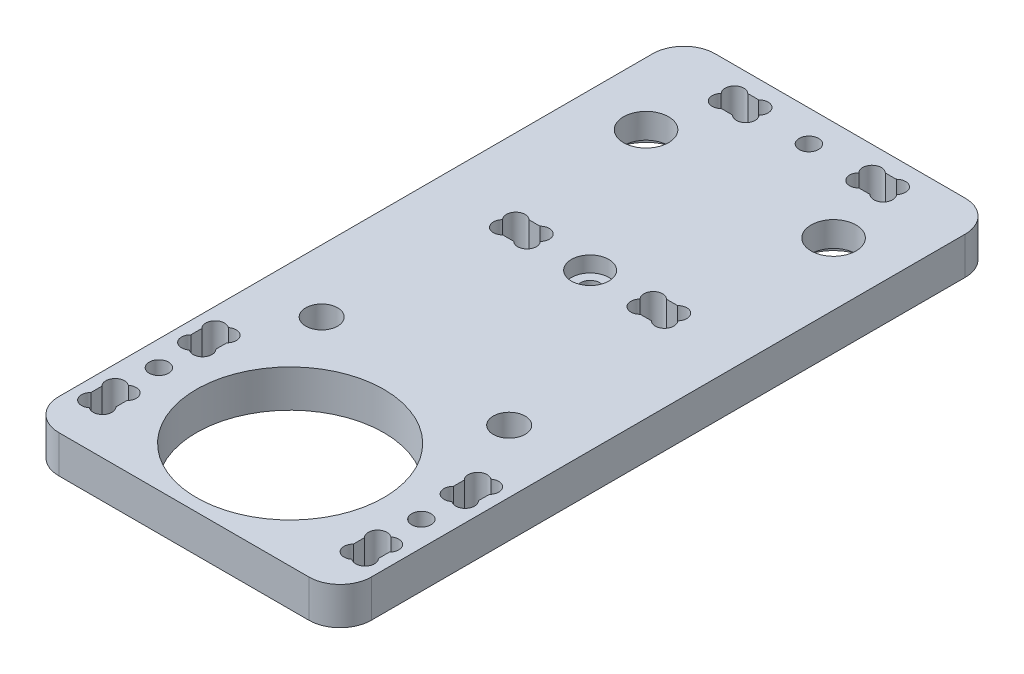
from build123d import *

# Parameters (mm, degrees)
CROQUIS1_W              = 50
CROQUIS1_H              = 105
SALIENTE_EXTRUIR1_DEPTH = 6
CROQUIS2_R              = 3.6
CROQUIS2_R_2            = 2.55
CORTAR_EXTRUIR2_DEPTH   = 7
CROQUIS4_R              = 6
CROQUIS4_R_2            = 5.05
CORTAR_EXTRUIR3_DEPTH   = 2
CROQUIS5_R              = 1.55
CROQUIS5_W              = 6
CROQUIS5_H              = 4.2
CORTAR_EXTRUIR4_DEPTH   = 7
CORTAR_EXTRUIR6_DEPTH   = 7
CROQUIS14_R             = 3
CORTAR_EXTRUIR9_DEPTH   = 2.5
CROQUIS16_R             = 15
CORTAR_EXTRUIR10_DEPTH  = 7
CROQUIS17_R             = 1.55
CROQUIS17_W             = 4
CROQUIS17_H             = 6
CORTAR_EXTRUIR11_DEPTH  = 7
REDONDEO1_R             = 5
CORTAR_EXTRUIR12_DEPTH  = 7


with BuildPart() as part:
    # Croquis1 → Saliente-Extruir1 (new body)
    with BuildSketch(Plane(origin=(0, 0, 0), x_dir=(1, 0, 0), z_dir=(0, 1, 0))):
        Rectangle(CROQUIS1_W, CROQUIS1_H)
    extrude(amount=SALIENTE_EXTRUIR1_DEPTH)

    # Croquis2 → Cortar-Extruir2 (cut, through all)
    with BuildSketch(Plane(origin=(0, 6, 0), x_dir=(1, 0, 0), z_dir=(0, 1, 0))):
        with Locations((-15, 36.45)):
            Circle(CROQUIS2_R)
        with Locations((15, 36.45)):
            Circle(CROQUIS2_R)
        with Locations((15, -15.45)):
            Circle(CROQUIS2_R_2)
        with Locations((-15, -15.45)):
            Circle(CROQUIS2_R_2)
    extrude(amount=-CORTAR_EXTRUIR2_DEPTH, mode=Mode.SUBTRACT)

    # Croquis4 → Cortar-Extruir3 (cut)
    with BuildSketch(Plane.XZ):
        with Locations((15, -36.45)):
            Circle(CROQUIS4_R)
        with Locations((-15, -36.45)):
            Circle(CROQUIS4_R)
        with Locations((-15, 15.45)):
            Circle(CROQUIS4_R_2)
        with Locations((15, 15.45)):
            Circle(CROQUIS4_R_2)
    extrude(amount=-CORTAR_EXTRUIR3_DEPTH, mode=Mode.SUBTRACT)

    # Croquis5 → Cortar-Extruir4 (cut, through all)
    with BuildSketch(Plane(origin=(0, 6, 0), x_dir=(1, 0, 0), z_dir=(0, 1, 0))):
        with Locations((0, 47.5)):
            Circle(CROQUIS5_R)
        with Locations((-11, 47.5)):
            Rectangle(CROQUIS5_W, CROQUIS5_H)
        with Locations((11, 47.5)):
            Rectangle(CROQUIS5_W, CROQUIS5_H)
    cortar_extruir4 = extrude(amount=-CORTAR_EXTRUIR4_DEPTH, mode=Mode.SUBTRACT)

    # Croquis8 → Cortar-Extruir6 (cut, through all)
    with BuildSketch(Plane(origin=(0, 6, 0), x_dir=(1, 0, 0), z_dir=(0, 1, 0))):
        with BuildLine():
            Line((-11.878679656, 49.6), (-10.121320344, 49.6))
            ThreePointArc((-10.121320344, 49.6), (-8.010608171, 49.610503119), (-7.979099854, 47.5))
            ThreePointArc((-7.979099854, 47.5), (-8.010608171, 45.389496881), (-10.121320344, 45.4))
            Line((-10.121320344, 45.4), (-11.878679656, 45.4))
            ThreePointArc((-11.878679656, 45.4), (-13.989391829, 45.389496881), (-14.020900146, 47.5))
            ThreePointArc((-14.020900146, 47.5), (-13.989391829, 49.610503119), (-11.878679656, 49.6))
        make_face()
        with BuildLine():
            Line((10.121320344, 45.4), (11.878679656, 45.4))
            ThreePointArc((11.878679656, 45.4), (13.989391829, 45.389496881), (14.020900146, 47.5))
            ThreePointArc((14.020900146, 47.5), (13.989391829, 49.610503119), (11.878679656, 49.6))
            Line((11.878679656, 49.6), (10.121320344, 49.6))
            ThreePointArc((10.121320344, 49.6), (8.010608171, 49.610503119), (7.979099854, 47.5))
            ThreePointArc((7.979099854, 47.5), (8.010608171, 45.389496881), (10.121320344, 45.4))
        make_face()
    cortar_extruir6 = extrude(amount=-CORTAR_EXTRUIR6_DEPTH, mode=Mode.SUBTRACT)

    # Simetría1: Cortar-Extruir4, Cortar-Extruir6 across plane
    add(cortar_extruir4.mirror(Plane.XY.offset(-30)), mode=Mode.SUBTRACT)
    add(cortar_extruir6.mirror(Plane.XY.offset(-30)), mode=Mode.SUBTRACT)

    # Croquis14 → Cortar-Extruir9 (cut)
    with BuildSketch(Plane(origin=(0, 6, 0), x_dir=(1, 0, 0), z_dir=(0, 1, 0))):
        with Locations((0, 12.5)):
            Circle(CROQUIS14_R)
    extrude(amount=-CORTAR_EXTRUIR9_DEPTH, mode=Mode.SUBTRACT)

    # Croquis16 → Cortar-Extruir10 (cut, through all)
    with BuildSketch(Plane.XZ):
        with Locations((0, 35.5)):
            Circle(CROQUIS16_R)
    extrude(amount=-CORTAR_EXTRUIR10_DEPTH, mode=Mode.SUBTRACT)

    # Croquis17 → Cortar-Extruir11 (cut, through all)
    with BuildSketch(Plane(origin=(0, 6, 0), x_dir=(1, 0, 0), z_dir=(0, 1, 0))):
        with Locations((21, -35.5)):
            Circle(CROQUIS17_R)
        with Locations((-21, -35.5)):
            Circle(CROQUIS17_R)
        with Locations((-21, -43.5)):
            Rectangle(CROQUIS17_W, CROQUIS17_H)
        with Locations((21, -43.5)):
            Rectangle(CROQUIS17_W, CROQUIS17_H)
        with Locations((21, -27.5)):
            Rectangle(CROQUIS17_W, CROQUIS17_H)
        with Locations((-21, -27.5)):
            Rectangle(CROQUIS17_W, CROQUIS17_H)
    extrude(amount=-CORTAR_EXTRUIR11_DEPTH, mode=Mode.SUBTRACT)

    # Redondeo1
    redondeo1_edges = [part.edges().sort_by_distance(p)[0] for p in [
        (25, 3, 52.5),
        (-25, 3, 52.5),
        (-25, 3, -52.5),
        (25, 3, -52.5),
    ]]
    fillet(redondeo1_edges, radius=REDONDEO1_R)

    # Croquis18 → Cortar-Extruir12 (cut, through all)
    with BuildSketch(Plane(origin=(0, 6, 0), x_dir=(1, 0, 0), z_dir=(0, 1, 0))):
        with BuildLine():
            ThreePointArc((-21, -24.391198464), (-23.439339828, -25.560660172), (-21, -26.73012188))
            ThreePointArc((-21, -26.73012188), (-18.560660172, -25.560660172), (-21, -24.391198464))
        make_face()
        with BuildLine():
            ThreePointArc((-21, -30.608801536), (-23.439339828, -29.439339828), (-21, -28.26987812))
            ThreePointArc((-21, -28.26987812), (-18.560660172, -29.439339828), (-21, -30.608801536))
        make_face()
        with BuildLine():
            ThreePointArc((-21, -46.608801536), (-18.560660172, -45.439339828), (-21, -44.26987812))
            ThreePointArc((-21, -44.26987812), (-23.439339828, -45.439339828), (-21, -46.608801536))
        make_face()
        with BuildLine():
            ThreePointArc((-21, -40.391198464), (-23.439339828, -41.560660172), (-21, -42.73012188))
            ThreePointArc((-21, -42.73012188), (-18.560660172, -41.560660172), (-21, -40.391198464))
        make_face()
        with BuildLine():
            ThreePointArc((21, -24.391198464), (18.560660172, -25.560660172), (21, -26.73012188))
            ThreePointArc((21, -26.73012188), (23.439339828, -25.560660172), (21, -24.391198464))
        make_face()
        with BuildLine():
            ThreePointArc((21, -30.608801536), (18.560660172, -29.439339828), (21, -28.26987812))
            ThreePointArc((21, -28.26987812), (23.439339828, -29.439339828), (21, -30.608801536))
        make_face()
        with BuildLine():
            ThreePointArc((21, -40.391198464), (18.560660172, -41.560660172), (21, -42.73012188))
            ThreePointArc((21, -42.73012188), (23.439339828, -41.560660172), (21, -40.391198464))
        make_face()
        with BuildLine():
            ThreePointArc((21, -46.608801536), (23.439339828, -45.439339828), (21, -44.26987812))
            ThreePointArc((21, -44.26987812), (18.560660172, -45.439339828), (21, -46.608801536))
        make_face()
    extrude(amount=-CORTAR_EXTRUIR12_DEPTH, mode=Mode.SUBTRACT)


solid = part.part
